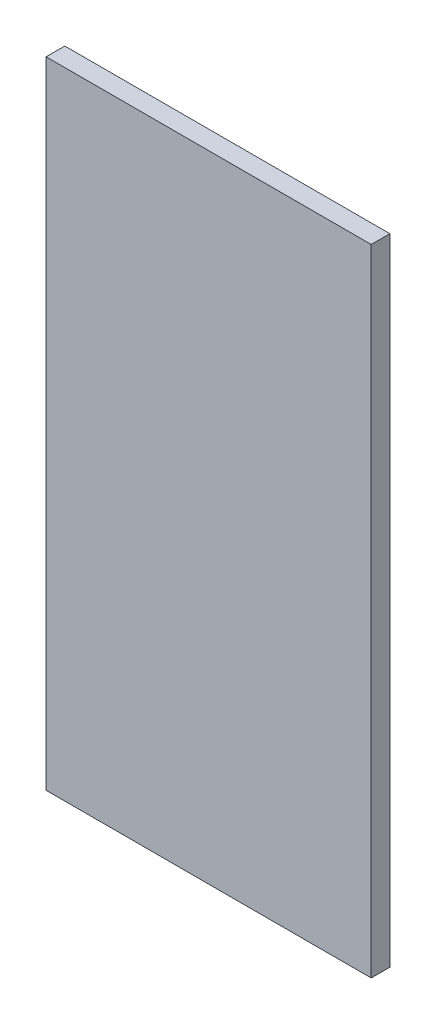
from build123d import *

# Parameters (mm, degrees)
SKETCH1_W           = 87
SKETCH1_H           = 170
BOSS_EXTRUDE2_DEPTH = 5


with BuildPart() as part:
    # Sketch1 → Boss-Extrude2 (new body)
    with BuildSketch(Plane.XY):
        with Locations((43.5, 85)):
            Rectangle(SKETCH1_W, SKETCH1_H)
    extrude(amount=BOSS_EXTRUDE2_DEPTH)


solid = part.part
